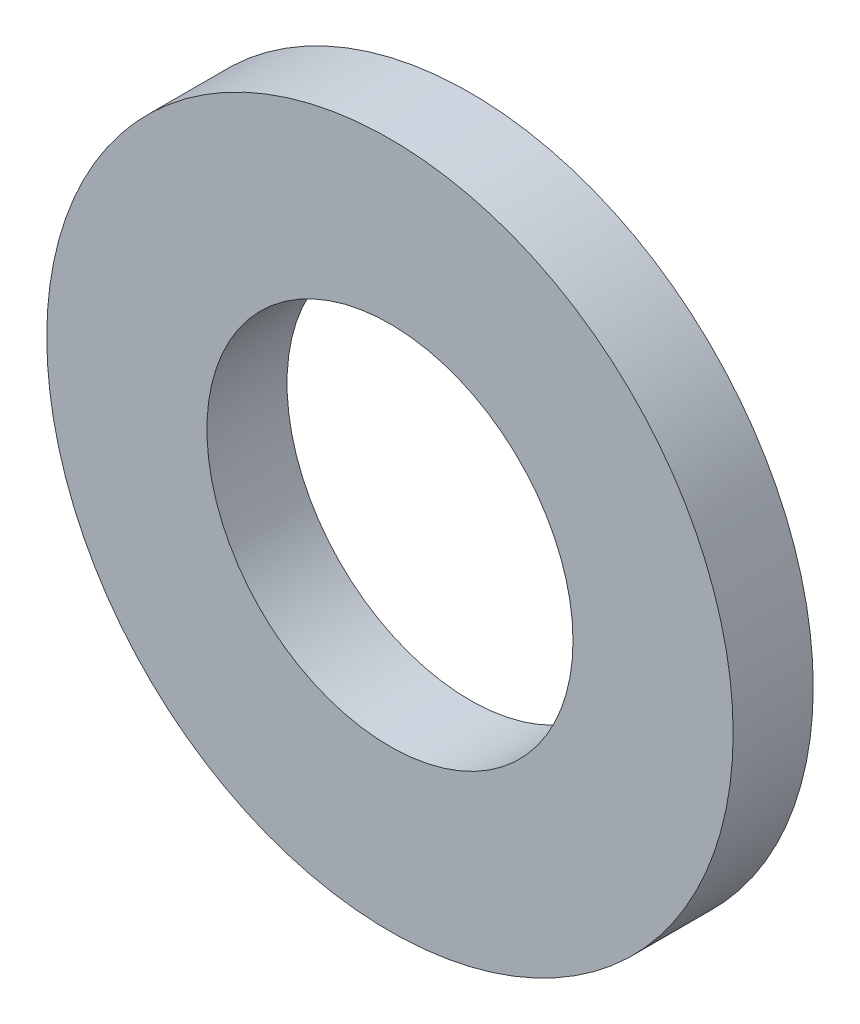
from build123d import *

# Parameters (mm, degrees)
SKETCH1_R      = 6
SKETCH1_R_2    = 3.2
EXTRUDE1_DEPTH = 1.4


with BuildPart() as part:
    # Sketch1 → Extrude1 (new body)
    with BuildSketch(Plane.XY):
        Circle(SKETCH1_R)
        Circle(SKETCH1_R_2, mode=Mode.SUBTRACT)
    extrude(amount=-EXTRUDE1_DEPTH)


solid = part.part
